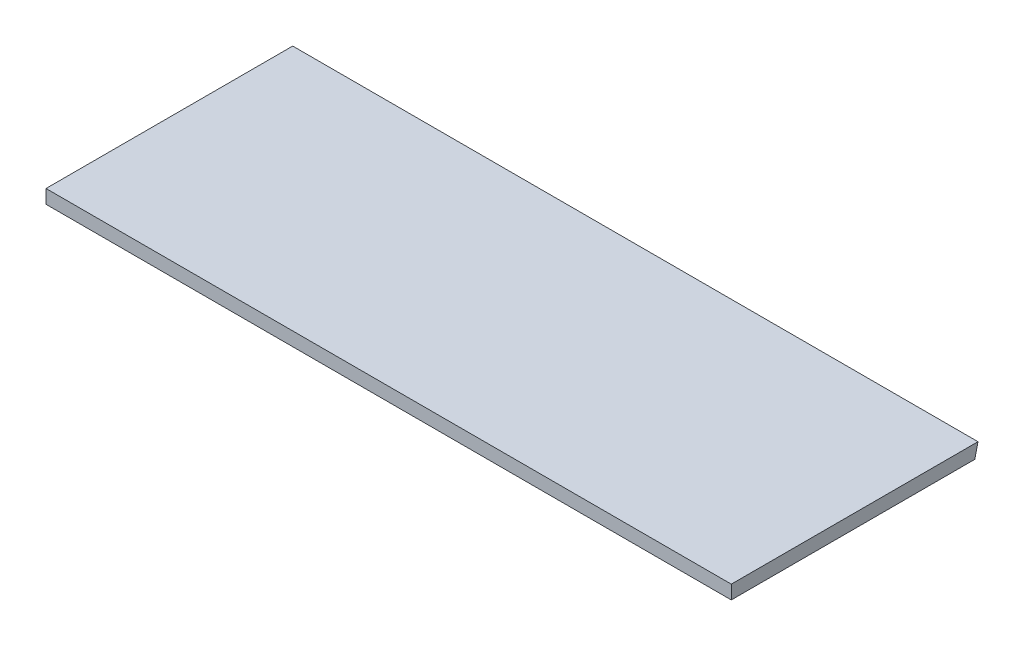
from build123d import *

# Parameters (mm, degrees)
SKETCH2_W           = 500
SKETCH2_H           = 180
BOSS_EXTRUDE1_DEPTH = 10
CUT_EXTRUDE4_DEPTH  = 501


with BuildPart() as part:
    # Sketch2 → Boss-Extrude1 (new body)
    with BuildSketch(Plane(origin=(0, 0, 0), x_dir=(1, 0, 0), z_dir=(0, 1, 0))):
        Rectangle(SKETCH2_W, SKETCH2_H)
    extrude(amount=BOSS_EXTRUDE1_DEPTH)

    # Sketch4 → Cut-Extrude4 (cut, through all)
    with BuildSketch(Plane(origin=(250, 0, 0), x_dir=(0, 0, -1), z_dir=(1, 0, 0))):
        Polygon((90, 10), (87.691318089, 0), (90, 0), align=None)
    extrude(amount=-CUT_EXTRUDE4_DEPTH, mode=Mode.SUBTRACT)


solid = part.part
